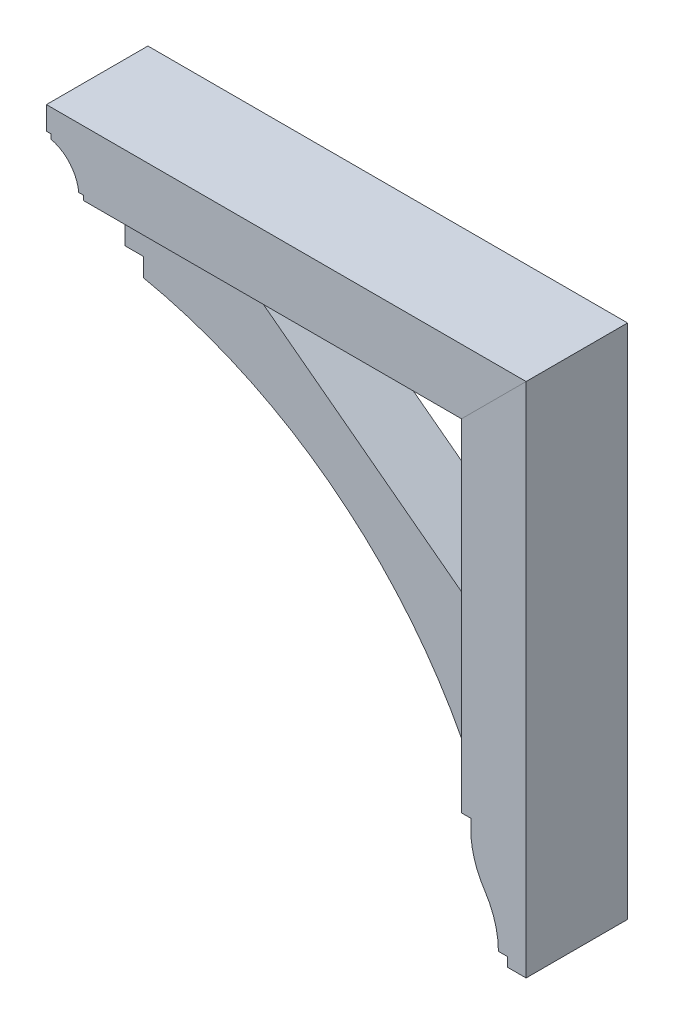
from build123d import *

# Parameters (mm, degrees)
BOSS_EXTRUDE1_DEPTH = 69.85
BOSS_EXTRUDE2_DEPTH = 44.45
BOSS_EXTRUDE3_DEPTH = 69.85


with BuildPart() as part:
    # Sketch1 → Boss-Extrude1 (new body, symmetric)
    with BuildSketch(Plane.XY):
        with BuildLine():
            Line((-330.968776984, 337.185), (-330.968776984, 343.535))
            Line((-330.968776984, 343.535), (-337.318776984, 343.535))
            Line((-337.318776984, 343.535), (-337.318776984, 375.285))
            Line((-337.318776984, 375.285), (323.081223016, 375.285))
            Line((323.081223016, 375.285), (234.181223016, 286.385))
            Line((234.181223016, 286.385), (-286.518776984, 286.385))
            Line((-286.518776984, 286.385), (-286.518776984, 292.735))
            Line((-286.518776984, 292.735), (-292.868776984, 292.735))
            ThreePointArc((-292.868776984, 292.735), (-304.860423906, 321.010016924), (-330.968776984, 337.185))
        make_face()
    extrude(amount=BOSS_EXTRUDE1_DEPTH, both=True)


with BuildPart() as body_2:
    # Sketch1_3 → Boss-Extrude2 (new body, symmetric)
    with BuildSketch(Plane.XY):
        with BuildLine():
            Line((234.181223016, 35.56), (-97.606276984, 286.385))
            Line((-97.606276984, 286.385), (-254.768776984, 286.385))
            Line((-254.768776984, 286.385), (-254.768776984, 235.585))
            Line((-254.768776984, 235.585), (-229.368776984, 235.585))
            Line((-229.368776984, 235.585), (-229.368776984, 210.185))
            ThreePointArc((-229.368776984, 210.185), (26.79686291, 94.301426014), (208.781223016, -120.015))
            Line((208.781223016, -120.015), (234.181223016, -120.015))
            Line((234.181223016, -120.015), (234.181223016, 35.56))
        make_face()
    extrude(amount=BOSS_EXTRUDE2_DEPTH, both=True)


with BuildPart() as body_3:
    # Sketch1_4 → Boss-Extrude3 (new body, symmetric)
    with BuildSketch(Plane.XY):
        with BuildLine():
            Line((323.081223016, -335.915), (323.081223016, 375.285))
            Line((323.081223016, 375.285), (234.181223016, 286.385))
            Line((234.181223016, 286.385), (234.181223016, -183.515))
            Line((234.181223016, -183.515), (246.881223016, -183.515))
            Line((246.881223016, -183.515), (246.881223016, -196.215))
            ThreePointArc((246.881223016, -196.215), (251.768629387, -229.515028089), (266.018608337, -260.006284404))
            ThreePointArc((266.018608337, -260.006284404), (280.138450492, -290.219081757), (284.981223016, -323.215))
            Line((284.981223016, -323.215), (297.681223016, -323.215))
            Line((297.681223016, -323.215), (297.681223016, -335.915))
            Line((297.681223016, -335.915), (323.081223016, -335.915))
        make_face()
    extrude(amount=BOSS_EXTRUDE3_DEPTH, both=True)


solid = Compound([part.part, body_2.part, body_3.part])
